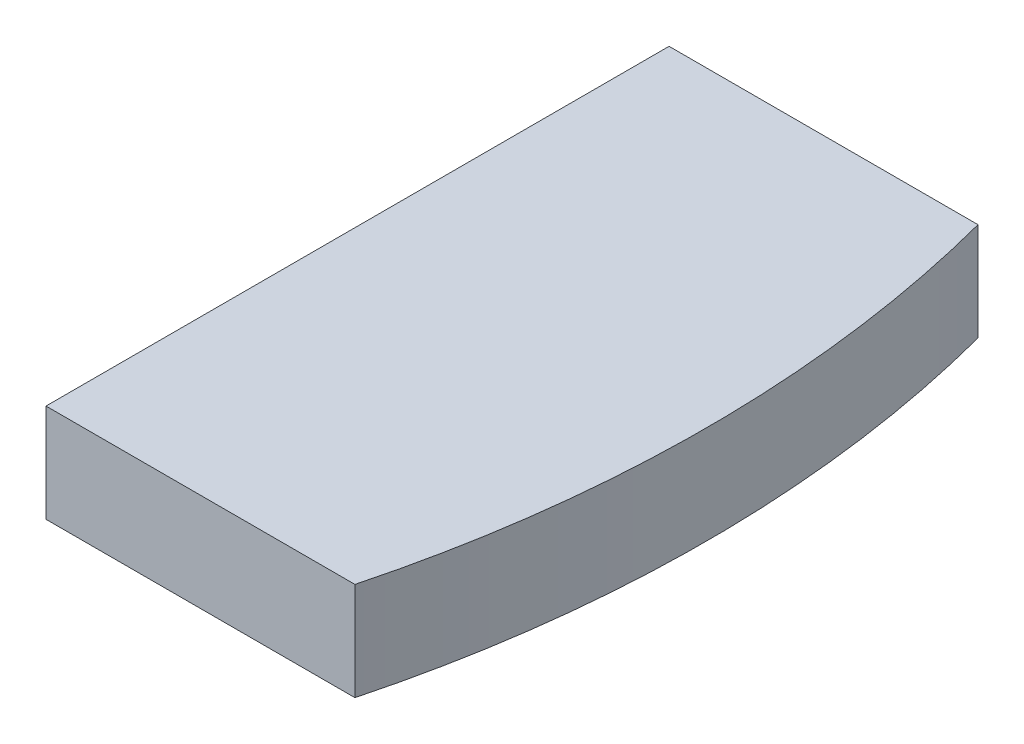
from build123d import *

# Parameters (mm, degrees)
SKETCH1_R           = 15
SKETCH1_R_2         = 5
BOSS_EXTRUDE1_DEPTH = 12
SKETCH3_R           = 5
SKETCH3_R_2         = 15
CUT_EXTRUDE4_DEPTH  = 13


with BuildPart() as part:
    # Sketch1 → Boss-Extrude1 (new body)
    with BuildSketch(Plane(origin=(0, 0, 0), x_dir=(1, 0, 0), z_dir=(0, 1, 0))):
        with BuildLine():
            Line((67.27241336, 38.839745962), (129.903810568, 75))
            ThreePointArc((129.903810568, 75), (150, 0), (129.903810568, -75))
            Line((129.903810568, -75), (67.27241336, -38.839745962))
            ThreePointArc((67.27241336, -38.839745962), (64.860603811, -37.840741737), (62.27241336, -37.5))
            Line((62.27241336, -37.5), (-45.048094716, -37.5))
            ThreePointArc((-45.048094716, -37.5), (-52.119162528, -34.571067812), (-55.048094716, -27.5))
            Line((-55.048094716, -27.5), (-55.048094716, 27.5))
            ThreePointArc((-55.048094716, 27.5), (-52.119162528, 34.571067812), (-45.048094716, 37.5))
            Line((-45.048094716, 37.5), (62.27241336, 37.5))
            ThreePointArc((62.27241336, 37.5), (64.860603811, 37.840741737), (67.27241336, 38.839745962))
        make_face()
        Circle(SKETCH1_R, mode=Mode.SUBTRACT)
        with Locations((30, 0)):
            Circle(SKETCH1_R_2, mode=Mode.SUBTRACT)
        with Locations((-30, 0)):
            Circle(SKETCH1_R_2, mode=Mode.SUBTRACT)
        with Locations((50, 0)):
            Circle(SKETCH1_R_2, mode=Mode.SUBTRACT)
    extrude(amount=BOSS_EXTRUDE1_DEPTH)

    # Sketch3 → Cut-Extrude4 (cut, through all)
    with BuildSketch(Plane(origin=(0, 12, 0), x_dir=(1, 0, 0), z_dir=(0, 1, 0))):
        with BuildLine():
            Line((107.3, -38.1), (107.3, 38.1))
            Line((107.3, 38.1), (145.080632753, 38.1))
            ThreePointArc((145.080632753, 38.1), (138.724595934, 57.056870602), (129.903810568, 75))
            Line((129.903810568, 75), (67.27241336, 38.839745962))
            ThreePointArc((67.27241336, 38.839745962), (64.860603811, 37.840741737), (62.27241336, 37.5))
            Line((62.27241336, 37.5), (-45.048094716, 37.5))
            ThreePointArc((-45.048094716, 37.5), (-52.119162528, 34.571067812), (-55.048094716, 27.5))
            Line((-55.048094716, 27.5), (-55.048094716, -27.5))
            ThreePointArc((-55.048094716, -27.5), (-52.119162528, -34.571067812), (-45.048094716, -37.5))
            Line((-45.048094716, -37.5), (62.27241336, -37.5))
            ThreePointArc((62.27241336, -37.5), (64.860603811, -37.840741737), (67.27241336, -38.839745962))
            Line((67.27241336, -38.839745962), (129.903810568, -75))
            ThreePointArc((129.903810568, -75), (138.724595934, -57.056870602), (145.080632753, -38.1))
            Line((145.080632753, -38.1), (107.3, -38.1))
        make_face()
        with Locations((-30, 0)):
            Circle(SKETCH3_R, mode=Mode.SUBTRACT)
        Circle(SKETCH3_R_2, mode=Mode.SUBTRACT)
        with Locations((30, 0)):
            Circle(SKETCH3_R, mode=Mode.SUBTRACT)
        with Locations((50, 0)):
            Circle(SKETCH3_R, mode=Mode.SUBTRACT)
    extrude(amount=-CUT_EXTRUDE4_DEPTH, mode=Mode.SUBTRACT)


solid = part.part
